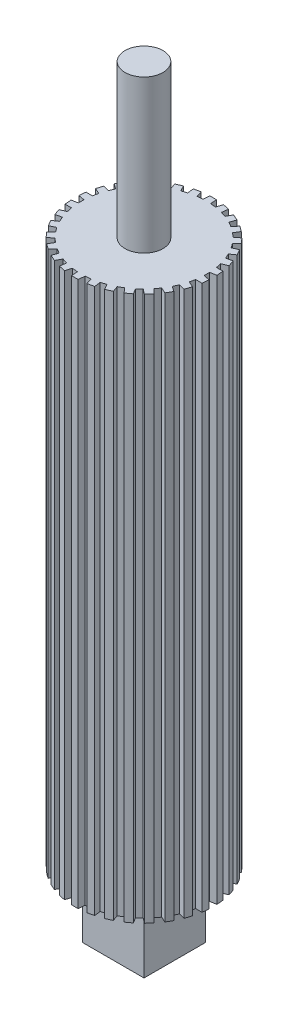
from build123d import *

# Parameters (mm, degrees)
BOSS_EXTRUDE1_DEPTH = 211.1375
SCALE2_SCALE_X      = 0.96
SCALE2_SCALE_Y      = 1
SCALE2_SCALE_Z      = 0.96
SKETCH3_R           = 3.68046
BOSS_EXTRUDE2_DEPTH = 29.55925
SKETCH4_R           = 3.68046
BOSS_EXTRUDE3_DEPTH = 29.55925
SKETCH5_R           = 17.959388275
CUT_EXTRUDE1_DEPTH  = 135.128
SKETCH6_W           = 11.938
SKETCH6_H           = 11.938
BOSS_EXTRUDE4_DEPTH = 12.7


with BuildPart() as part:
    # Sketch2 → Boss-Extrude1 (new body)
    with BuildSketch(Plane(origin=(0, 0, 0), x_dir=(1, 0, 0), z_dir=(0, 1, 0))):
        with BuildLine():
            Line((-0.775316452, 12.67631194), (-0.670254455, 13.953911959))
            ThreePointArc((-0.670254455, 13.953911959), (0, 13.97), (0.670254455, 13.953911959))
            Line((0.670254455, 13.953911959), (0.775316452, 12.67631194))
            ThreePointArc((0.775316452, 12.67631194), (1.327511483, 12.630428071), (1.877179521, 12.560501465))
            Line((1.877179521, 12.560501465), (2.245573641, 13.788339241))
            ThreePointArc((2.245573641, 13.788339241), (2.904526321, 13.664721982), (3.556789216, 13.509631767))
            Line((3.556789216, 13.509631767), (3.393927376, 12.238106756))
            ThreePointArc((3.393927376, 12.238106756), (3.924515829, 12.078417757), (4.447633742, 11.895736803))
            Line((4.447633742, 11.895736803), (5.063259395, 13.020149934))
            ThreePointArc((5.063259395, 13.020149934), (5.682110904, 12.762230043), (6.287875221, 12.474915839))
            Line((6.287875221, 12.474915839), (5.864207388, 11.265037581))
            ThreePointArc((5.864207388, 11.265037581), (6.35, 10.998522628), (6.823705026, 10.711071362))
            Line((6.823705026, 10.711071362), (7.659656416, 11.682917597))
            ThreePointArc((7.659656416, 11.682917597), (8.211359975, 11.301967411), (8.744150906, 10.894986229))
            Line((8.744150906, 10.894986229), (8.078193398, 9.799632209))
            ThreePointArc((8.078193398, 9.799632209), (8.497958701, 9.437939284), (8.901547657, 9.058280704))
            Line((8.901547657, 9.058280704), (9.921289697, 9.835085701))
            ThreePointArc((9.921289697, 9.835085701), (10.381733212, 9.347754571), (10.818265238, 8.83889344))
            Line((10.818265238, 8.83889344), (9.939123592, 7.905935885))
            ThreePointArc((9.939123592, 7.905935885), (10.274515829, 7.464872704), (10.59034994, 7.009599713))
            Line((10.59034994, 7.009599713), (11.749315011, 7.557413365))
            ThreePointArc((11.749315011, 7.557413365), (12.098374891, 6.985), (12.419569467, 6.396498594))
            Line((12.419569467, 6.396498594), (11.365666392, 5.666712226))
            ThreePointArc((11.365666392, 5.666712226), (11.602027312, 5.165555367), (11.816303113, 4.654565579))
            Line((11.816303113, 4.654565579), (13.063838879, 4.949445801))
            ThreePointArc((13.063838879, 4.949445801), (13.286259533, 4.316967411), (13.478078914, 3.674546066))
            Line((13.478078914, 3.674546066), (12.295475033, 3.179826051))
            ThreePointArc((12.295475033, 3.179826051), (12.422474529, 2.640478473), (12.52582714, 2.096104594))
            Line((12.52582714, 2.096104594), (13.807410301, 2.125163705))
            ThreePointArc((13.807410301, 2.125163705), (13.893470878, 1.460262632), (13.947531638, 0.791998242))
            Line((13.947531638, 0.791998242), (12.687912414, 0.55396622))
            ThreePointArc((12.687912414, 0.55396622), (12.7, 0), (12.687912414, -0.55396622))
            Line((12.687912414, -0.55396622), (13.947531638, -0.791998242))
            ThreePointArc((13.947531638, -0.791998242), (13.893470878, -1.460262632), (13.807410301, -2.125163705))
            Line((13.807410301, -2.125163705), (12.52582714, -2.096104594))
            ThreePointArc((12.52582714, -2.096104594), (12.422474529, -2.640478473), (12.295475033, -3.179826051))
            Line((12.295475033, -3.179826051), (13.478078914, -3.674546066))
            ThreePointArc((13.478078914, -3.674546066), (13.286259533, -4.316967411), (13.063838879, -4.949445801))
            Line((13.063838879, -4.949445801), (11.816303113, -4.654565579))
            ThreePointArc((11.816303113, -4.654565579), (11.602027312, -5.165555367), (11.365666392, -5.666712226))
            Line((11.365666392, -5.666712226), (12.419569467, -6.396498594))
            ThreePointArc((12.419569467, -6.396498594), (12.098374891, -6.985), (11.749315011, -7.557413365))
            Line((11.749315011, -7.557413365), (10.59034994, -7.009599713))
            ThreePointArc((10.59034994, -7.009599713), (10.274515829, -7.464872704), (9.939123592, -7.905935885))
            Line((9.939123592, -7.905935885), (10.818265238, -8.83889344))
            ThreePointArc((10.818265238, -8.83889344), (10.381733212, -9.347754571), (9.921289697, -9.835085701))
            Line((9.921289697, -9.835085701), (8.901547657, -9.058280704))
            ThreePointArc((8.901547657, -9.058280704), (8.497958701, -9.437939284), (8.078193398, -9.799632209))
            Line((8.078193398, -9.799632209), (8.744150906, -10.894986229))
            ThreePointArc((8.744150906, -10.894986229), (8.211359975, -11.301967411), (7.659656416, -11.682917597))
            Line((7.659656416, -11.682917597), (6.823705026, -10.711071362))
            ThreePointArc((6.823705026, -10.711071362), (6.35, -10.998522628), (5.864207388, -11.265037581))
            Line((5.864207388, -11.265037581), (6.287875221, -12.474915839))
            ThreePointArc((6.287875221, -12.474915839), (5.682110904, -12.762230043), (5.063259395, -13.020149934))
            Line((5.063259395, -13.020149934), (4.447633742, -11.895736803))
            ThreePointArc((4.447633742, -11.895736803), (3.924515829, -12.078417757), (3.393927376, -12.238106756))
            Line((3.393927376, -12.238106756), (3.556789216, -13.509631767))
            ThreePointArc((3.556789216, -13.509631767), (2.904526321, -13.664721982), (2.245573641, -13.788339241))
            Line((2.245573641, -13.788339241), (1.877179521, -12.560501465))
            ThreePointArc((1.877179521, -12.560501465), (1.327511483, -12.630428071), (0.775316452, -12.67631194))
            Line((0.775316452, -12.67631194), (0.670254455, -13.953911959))
            ThreePointArc((0.670254455, -13.953911959), (0, -13.97), (-0.670254455, -13.953911959))
            Line((-0.670254455, -13.953911959), (-0.775316452, -12.67631194))
            ThreePointArc((-0.775316452, -12.67631194), (-1.327511483, -12.630428071), (-1.877179521, -12.560501465))
            Line((-1.877179521, -12.560501465), (-2.245573641, -13.788339241))
            ThreePointArc((-2.245573641, -13.788339241), (-2.904526321, -13.664721982), (-3.556789216, -13.509631767))
            Line((-3.556789216, -13.509631767), (-3.393927376, -12.238106756))
            ThreePointArc((-3.393927376, -12.238106756), (-3.924515829, -12.078417757), (-4.447633742, -11.895736803))
            Line((-4.447633742, -11.895736803), (-5.063259395, -13.020149934))
            ThreePointArc((-5.063259395, -13.020149934), (-5.682110904, -12.762230043), (-6.287875221, -12.474915839))
            Line((-6.287875221, -12.474915839), (-5.864207388, -11.265037581))
            ThreePointArc((-5.864207388, -11.265037581), (-6.35, -10.998522628), (-6.823705026, -10.711071362))
            Line((-6.823705026, -10.711071362), (-7.659656416, -11.682917597))
            ThreePointArc((-7.659656416, -11.682917597), (-8.211359975, -11.301967411), (-8.744150906, -10.894986229))
            Line((-8.744150906, -10.894986229), (-8.078193398, -9.799632209))
            ThreePointArc((-8.078193398, -9.799632209), (-8.497958701, -9.437939284), (-8.901547657, -9.058280704))
            Line((-8.901547657, -9.058280704), (-9.921289697, -9.835085701))
            ThreePointArc((-9.921289697, -9.835085701), (-10.381733212, -9.347754571), (-10.818265238, -8.83889344))
            Line((-10.818265238, -8.83889344), (-9.939123592, -7.905935885))
            ThreePointArc((-9.939123592, -7.905935885), (-10.274515829, -7.464872704), (-10.59034994, -7.009599713))
            Line((-10.59034994, -7.009599713), (-11.749315011, -7.557413365))
            ThreePointArc((-11.749315011, -7.557413365), (-12.098374891, -6.985), (-12.419569467, -6.396498594))
            Line((-12.419569467, -6.396498594), (-11.365666392, -5.666712226))
            ThreePointArc((-11.365666392, -5.666712226), (-11.602027312, -5.165555367), (-11.816303113, -4.654565579))
            Line((-11.816303113, -4.654565579), (-13.063838879, -4.949445801))
            ThreePointArc((-13.063838879, -4.949445801), (-13.286259533, -4.316967411), (-13.478078914, -3.674546066))
            Line((-13.478078914, -3.674546066), (-12.295475033, -3.179826051))
            ThreePointArc((-12.295475033, -3.179826051), (-12.422474529, -2.640478473), (-12.52582714, -2.096104594))
            Line((-12.52582714, -2.096104594), (-13.807410301, -2.125163705))
            ThreePointArc((-13.807410301, -2.125163705), (-13.893470878, -1.460262632), (-13.947531638, -0.791998242))
            Line((-13.947531638, -0.791998242), (-12.687912414, -0.55396622))
            ThreePointArc((-12.687912414, -0.55396622), (-12.7, 0), (-12.687912414, 0.55396622))
            Line((-12.687912414, 0.55396622), (-13.947531638, 0.791998242))
            ThreePointArc((-13.947531638, 0.791998242), (-13.893470878, 1.460262632), (-13.807410301, 2.125163705))
            Line((-13.807410301, 2.125163705), (-12.52582714, 2.096104594))
            ThreePointArc((-12.52582714, 2.096104594), (-12.422474529, 2.640478473), (-12.295475033, 3.179826051))
            Line((-12.295475033, 3.179826051), (-13.478078914, 3.674546066))
            ThreePointArc((-13.478078914, 3.674546066), (-13.286259533, 4.316967411), (-13.063838879, 4.949445801))
            Line((-13.063838879, 4.949445801), (-11.816303113, 4.654565579))
            ThreePointArc((-11.816303113, 4.654565579), (-11.602027312, 5.165555367), (-11.365666392, 5.666712226))
            Line((-11.365666392, 5.666712226), (-12.419569467, 6.396498594))
            ThreePointArc((-12.419569467, 6.396498594), (-12.098374891, 6.985), (-11.749315011, 7.557413365))
            Line((-11.749315011, 7.557413365), (-10.59034994, 7.009599713))
            ThreePointArc((-10.59034994, 7.009599713), (-10.274515829, 7.464872704), (-9.939123592, 7.905935885))
            Line((-9.939123592, 7.905935885), (-10.818265238, 8.83889344))
            ThreePointArc((-10.818265238, 8.83889344), (-10.381733212, 9.347754571), (-9.921289697, 9.835085701))
            Line((-9.921289697, 9.835085701), (-8.901547657, 9.058280704))
            ThreePointArc((-8.901547657, 9.058280704), (-8.497958701, 9.437939284), (-8.078193398, 9.799632209))
            Line((-8.078193398, 9.799632209), (-8.744150906, 10.894986229))
            ThreePointArc((-8.744150906, 10.894986229), (-8.211359975, 11.301967411), (-7.659656416, 11.682917597))
            Line((-7.659656416, 11.682917597), (-6.823705026, 10.711071362))
            ThreePointArc((-6.823705026, 10.711071362), (-6.35, 10.998522628), (-5.864207388, 11.265037581))
            Line((-5.864207388, 11.265037581), (-6.287875221, 12.474915839))
            ThreePointArc((-6.287875221, 12.474915839), (-5.682110904, 12.762230043), (-5.063259395, 13.020149934))
            Line((-5.063259395, 13.020149934), (-4.447633742, 11.895736803))
            ThreePointArc((-4.447633742, 11.895736803), (-3.924515829, 12.078417757), (-3.393927376, 12.238106756))
            Line((-3.393927376, 12.238106756), (-3.556789216, 13.509631767))
            ThreePointArc((-3.556789216, 13.509631767), (-2.904526321, 13.664721982), (-2.245573641, 13.788339241))
            Line((-2.245573641, 13.788339241), (-1.877179521, 12.560501465))
            ThreePointArc((-1.877179521, 12.560501465), (-1.327511483, 12.630428071), (-0.775316452, 12.67631194))
        make_face()
    extrude(amount=BOSS_EXTRUDE1_DEPTH)


with BuildPart() as part_1:
    # Scale2: scaled about (0, 105.56875, 0)
    add(part.part.scale((SCALE2_SCALE_X, SCALE2_SCALE_Y, SCALE2_SCALE_Z), about=(0, 105.56875, 0)))

    # Sketch3 → Boss-Extrude2 (add)
    with BuildSketch(Plane(origin=(0, 211.1375, 0), x_dir=(1, 0, 0), z_dir=(0, 1, 0))):
        Circle(SKETCH3_R)
    extrude(amount=BOSS_EXTRUDE2_DEPTH)

    # Sketch4 → Boss-Extrude3 (add)
    with BuildSketch(Plane(origin=(0, 0, 0), x_dir=(-1, 0, 0), z_dir=(0, -1, 0))):
        Circle(SKETCH4_R)
    extrude(amount=BOSS_EXTRUDE3_DEPTH)

    # Sketch5 → Cut-Extrude1 (cut)
    with BuildSketch(Plane.XZ.offset(29.55925)):
        Circle(SKETCH5_R)
    extrude(amount=-CUT_EXTRUDE1_DEPTH, mode=Mode.SUBTRACT)

    # Sketch6 → Boss-Extrude4 (add)
    with BuildSketch(Plane.XZ.offset(-105.56875)):
        Rectangle(SKETCH6_W, SKETCH6_H)
    extrude(amount=BOSS_EXTRUDE4_DEPTH)


solid = part_1.part
